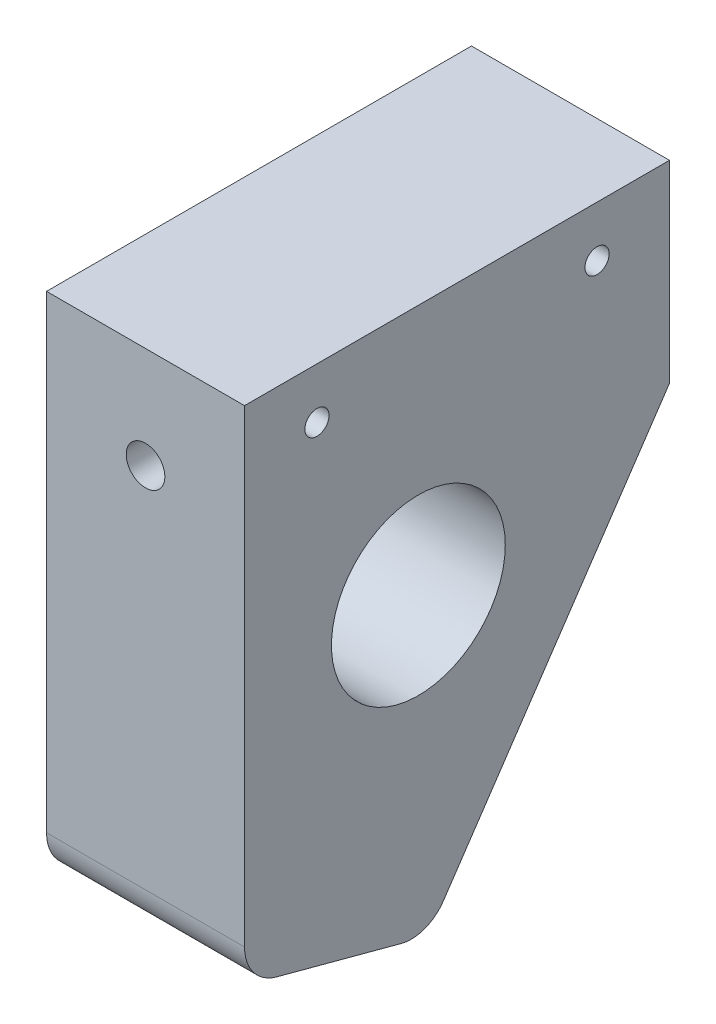
from build123d import *

# Parameters (mm, degrees)
SKETCH_1_R          = 9
SKETCH_1_R_2        = 1.25
EXTRUDE_1_DEPTH     = 10.25
SKETCH_2_R          = 2
CUT_EXTRUDE_1_DEPTH = 45


with BuildPart() as part:
    # 草圖1 → 填料-伸長1 (new body, symmetric)
    with BuildSketch(Plane(origin=(0, 0, 0), x_dir=(0, 0, -1), z_dir=(1, 0, 0))):
        with BuildLine():
            Line((-44, 0), (-44, -48.547028554))
            ThreePointArc((-44, -48.547028554), (-43.070090031, -51.286454985), (-40.664685703, -52.893694772))
            Line((-40.664685703, -52.893694772), (-27.771382825, -56.348444866))
            ThreePointArc((-27.771382825, -56.348444866), (-25.335277119, -56.231430318), (-23.419956354, -54.721513175))
            Line((-23.419956354, -54.721513175), (0, -20))
            Line((0, -20), (0, 0))
            Line((0, 0), (-44, 0))
        make_face()
        with Locations((-26, -26)):
            Circle(SKETCH_1_R, mode=Mode.SUBTRACT)
        with Locations((-36.5, -5.25)):
            Circle(SKETCH_1_R_2, mode=Mode.SUBTRACT)
        with Locations((-7.5, -5.25)):
            Circle(SKETCH_1_R_2, mode=Mode.SUBTRACT)
    extrude(amount=EXTRUDE_1_DEPTH, both=True)

    # 草圖2 → 除料-伸長1 (cut, through all)
    with BuildSketch(Plane.XY.offset(44)):
        with Locations((0, -10.5)):
            Circle(SKETCH_2_R)
    extrude(amount=-CUT_EXTRUDE_1_DEPTH, mode=Mode.SUBTRACT)


solid = part.part
